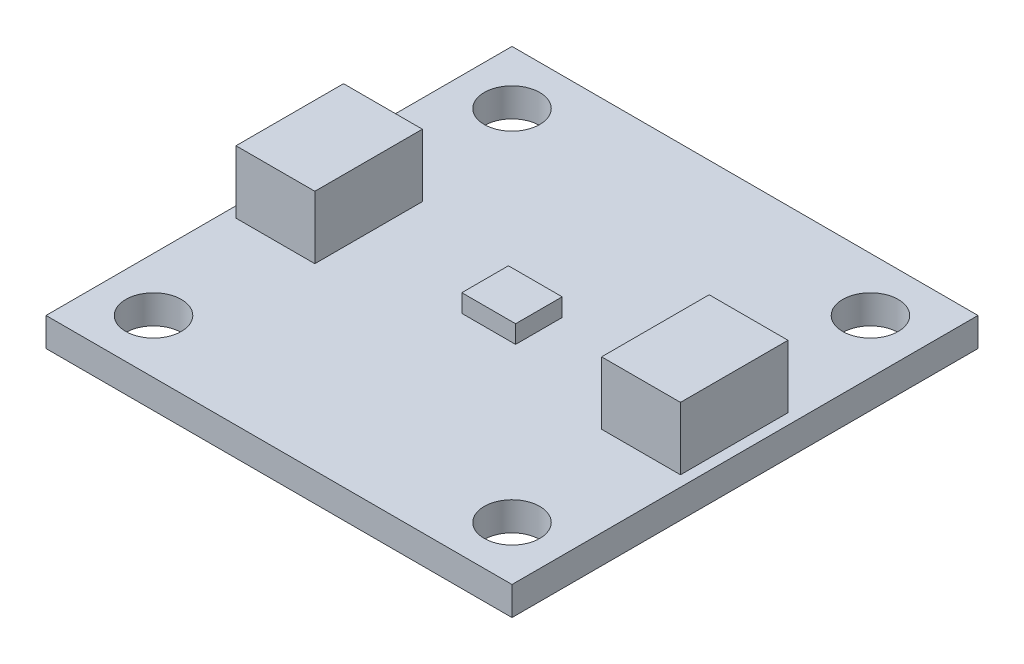
from build123d import *

# Parameters (mm, degrees)
SKETCH1_W           = 26
SKETCH1_H           = 26
SKETCH1_R           = 1.55
BOSS_EXTRUDE1_DEPTH = 1.6
SKETCH2_W           = 4.4
SKETCH2_H           = 6
BOSS_EXTRUDE2_DEPTH = 3.5
SKETCH3_W           = 3
SKETCH3_H           = 2.6
BOSS_EXTRUDE3_DEPTH = 1


with BuildPart() as part:
    # Sketch1 → Boss-Extrude1 (new body)
    with BuildSketch(Plane(origin=(0, 0, 0), x_dir=(1, 0, 0), z_dir=(0, 1, 0))):
        Rectangle(SKETCH1_W, SKETCH1_H)
        with Locations((-10, 10)):
            Circle(SKETCH1_R, mode=Mode.SUBTRACT)
        with Locations((10, 10)):
            Circle(SKETCH1_R, mode=Mode.SUBTRACT)
        with Locations((10, -10)):
            Circle(SKETCH1_R, mode=Mode.SUBTRACT)
        with Locations((-10, -10)):
            Circle(SKETCH1_R, mode=Mode.SUBTRACT)
    extrude(amount=BOSS_EXTRUDE1_DEPTH)

    # Sketch2 → Boss-Extrude2 (add)
    with BuildSketch(Plane(origin=(0, 1.6, 0), x_dir=(1, 0, 0), z_dir=(0, 1, 0))):
        with Locations((-10.2, 0)):
            Rectangle(SKETCH2_W, SKETCH2_H)
        with Locations((10.2, 0)):
            Rectangle(SKETCH2_W, SKETCH2_H)
    extrude(amount=BOSS_EXTRUDE2_DEPTH)

    # Sketch3 → Boss-Extrude3 (add)
    with BuildSketch(Plane(origin=(0, 1.6, 0), x_dir=(1, 0, 0), z_dir=(0, 1, 0))):
        Rectangle(SKETCH3_W, SKETCH3_H)
    extrude(amount=BOSS_EXTRUDE3_DEPTH)


solid = part.part
